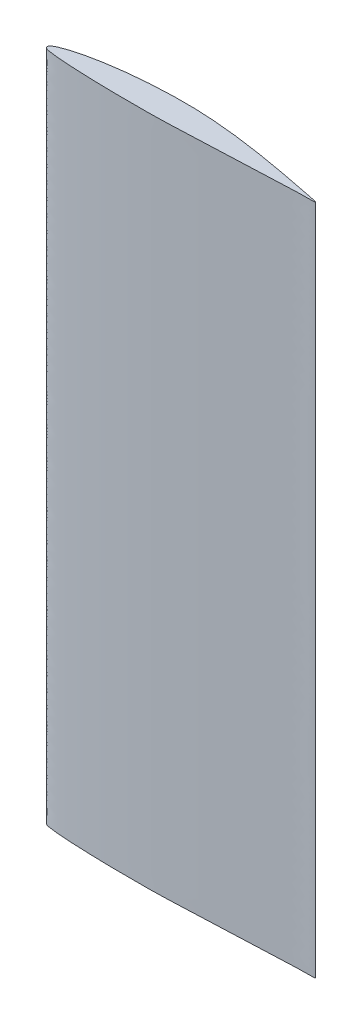
from build123d import *

# Parameters (mm, degrees)
BOSS_EXTRUDE1_DEPTH = 250


with BuildPart() as part:
    # Sketch1 → Boss-Extrude1 (new body)
    with BuildSketch(Plane(origin=(0, 0, 0), x_dir=(1, 0, 0), z_dir=(0, 1, 0))):
        with BuildLine():
            add(Edge.make_bspline(
                [(100, 0), (100.026927671, 0.219433858), (94.268719045, 1.183576039), (90.278291939, 2.083189014), (85.041517129, 3.079890056), (80.126408245, 3.982759073), (75.112008277, 4.832594532), (70.111065835, 5.599562513), (65.09404388, 6.272649179), (60.070772801, 6.843459682), (55.039557027, 7.289905462), (50.002635321, 7.600181442), (44.960674037, 7.725872882), (39.918014316, 7.698085219), (34.8760375, 7.519003187), (29.835349482, 7.210140329), (24.796607714, 6.762437252), (19.762507682, 6.15353518), (14.731061833, 5.376130555), (9.706731621, 4.364047298), (5.529220868, 3.27399749), (2.657163223, 2.209252647), (1.263899528, 1.576180331), (0.635088126, 1.149702618), (0.180823596, 0.758118254), (-0.251357417, -0.053698208), (0.472849839, -0.563654736), (1.001908694, -0.773847466), (1.694516894, -0.954370998), (3.137645534, -1.152917633), (5.244590793, -1.385513658), (7.759116968, -1.578504062), (11.09165954, -1.795176915), (15.247211424, -1.983192086), (20.224881618, -2.156849623), (25.194649087, -2.26881001), (31.812215076, -2.356756641), (38.42734188, -2.354724985), (46.697569516, -2.215932068), (53.311936654, -1.882969742), (59.935626694, -1.625222246), (64.911770343, -1.421263409), (69.897751183, -1.220146083), (74.886523022, -1.017029656), (79.908724272, -0.816125999), (84.853489661, -0.606576665), (90.137785468, -0.426514526), (94.198062583, -0.134726969), (99.973304112, -0.217545051), (100, 0)],
                knots=[0, 0, 0, 0, 0.025098604, 0.050110308, 0.075131372, 0.100155101, 0.125174498, 0.150180025, 0.17516549, 0.200126912, 0.225061594, 0.24997091, 0.274861189, 0.299750368, 0.324652268, 0.349579287, 0.37454444, 0.399567461, 0.42467622, 0.44992995, 0.475469787, 0.488517682, 0.49525113, 0.498115347, 0.499656141, 0.504317403, 0.508820397, 0.510252973, 0.512928796, 0.519316538, 0.531865303, 0.544297815, 0.556674285, 0.581327679, 0.605908743, 0.630446609, 0.654955943, 0.703934737, 0.728422961, 0.777461819, 0.802016771, 0.826605821, 0.851234377, 0.875908913, 0.90063284, 0.925408667, 0.950238345, 0.975117436, 1, 1, 1, 1], degree=3))
        make_face()
    extrude(amount=BOSS_EXTRUDE1_DEPTH)


solid = part.part
